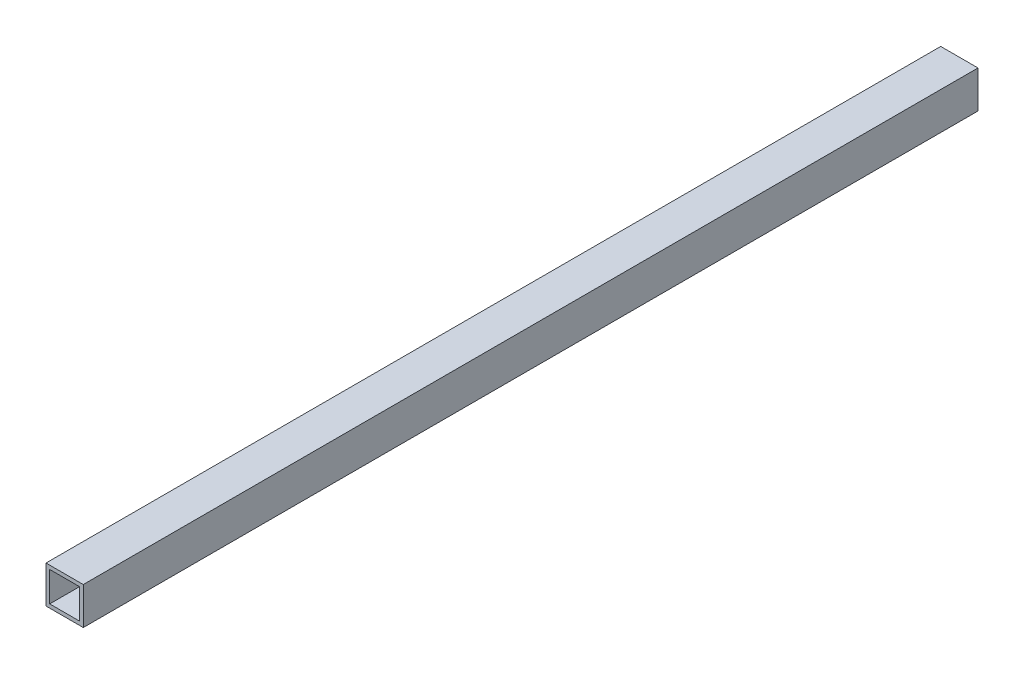
from build123d import *

# Parameters (mm, degrees)
SKETCH1_W   = 40
SKETCH1_H   = 40
SKETCH1_W_2 = 32
SKETCH1_H_2 = 32


with BuildPart() as part:
    # Sweep1: sweep along a curve in space
    with BuildLine() as sweep1_path:
        add(Edge.make_bspline(
            [(0, 0, -460), (0, 0, 500)],
            knots=[0, 0, 1, 1], degree=1))
    # Sketch1 → Sweep1 (sweep)
    with BuildSketch(Plane.XY):
        Rectangle(SKETCH1_W, SKETCH1_H)
        Rectangle(SKETCH1_W_2, SKETCH1_H_2, mode=Mode.SUBTRACT)
    sweep(path=sweep1_path.line)


solid = part.part
